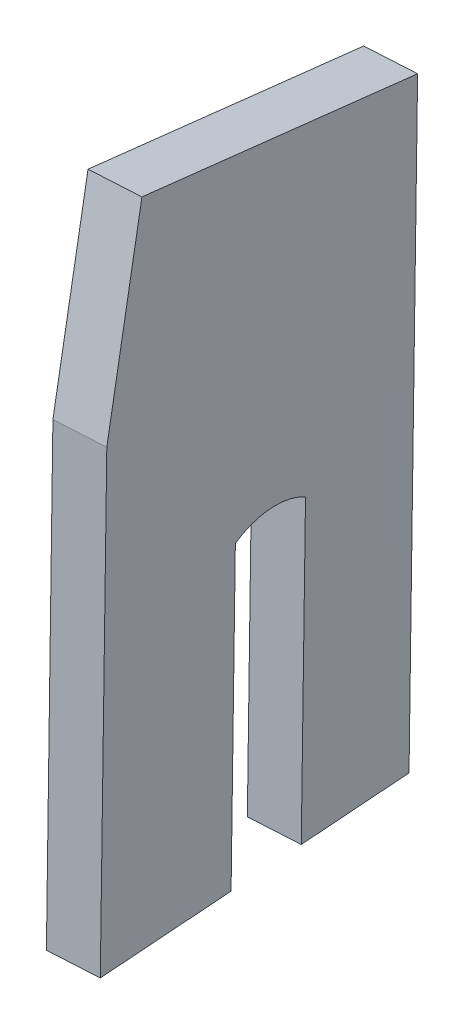
from build123d import *

# Parameters (mm, degrees)
BOSS_EXTRUDE1_DEPTH = 6.35


with BuildPart() as part:
    # Sketch1 → Boss-Extrude1 (new body)
    with BuildSketch(Plane(origin=(120.340372588, -1.499994886, -8.506893725), x_dir=(-0.07052518, -0.000878797, -0.997509612), z_dir=(0.997433673, -0.012432614, -0.070508858))):
        with BuildLine():
            Line((-157.673617622, -825.993121633), (-163.677010897, -824.934561423))
            Line((-163.677010897, -824.934561423), (-168.063361205, -850.003924474))
            Line((-168.063361205, -850.003924474), (-168.063361205, -908.15821278))
            Line((-168.063361205, -908.15821278), (-150.310627761, -908.15821278))
            Line((-150.310627761, -908.15821278), (-150.310627761, -870.05821278))
            ThreePointArc((-150.310627761, -870.05821278), (-145.548127761, -868.782104751), (-140.785627761, -870.05821278))
            Line((-140.785627761, -870.05821278), (-140.785627761, -908.15821278))
            Line((-140.785627761, -908.15821278), (-126.155802929, -908.15821278))
            Line((-126.155802929, -908.15821278), (-126.155802929, -831.550562736))
            Line((-126.155802929, -831.550562736), (-132.159196204, -830.492002526))
            Line((-132.159196204, -830.492002526), (-136.538277842, -855.519822856))
            Line((-136.538277842, -855.519822856), (-162.058583421, -851.054571785))
            Line((-162.058583421, -851.054571785), (-157.673617622, -825.993121633))
        make_face()
        Polygon((-132.159196204, -830.492002526), (-157.673617622, -825.993121633), (-162.058583421, -851.054571785), (-136.538277842, -855.519822856), align=None)
    extrude(amount=BOSS_EXTRUDE1_DEPTH)


solid = part.part
